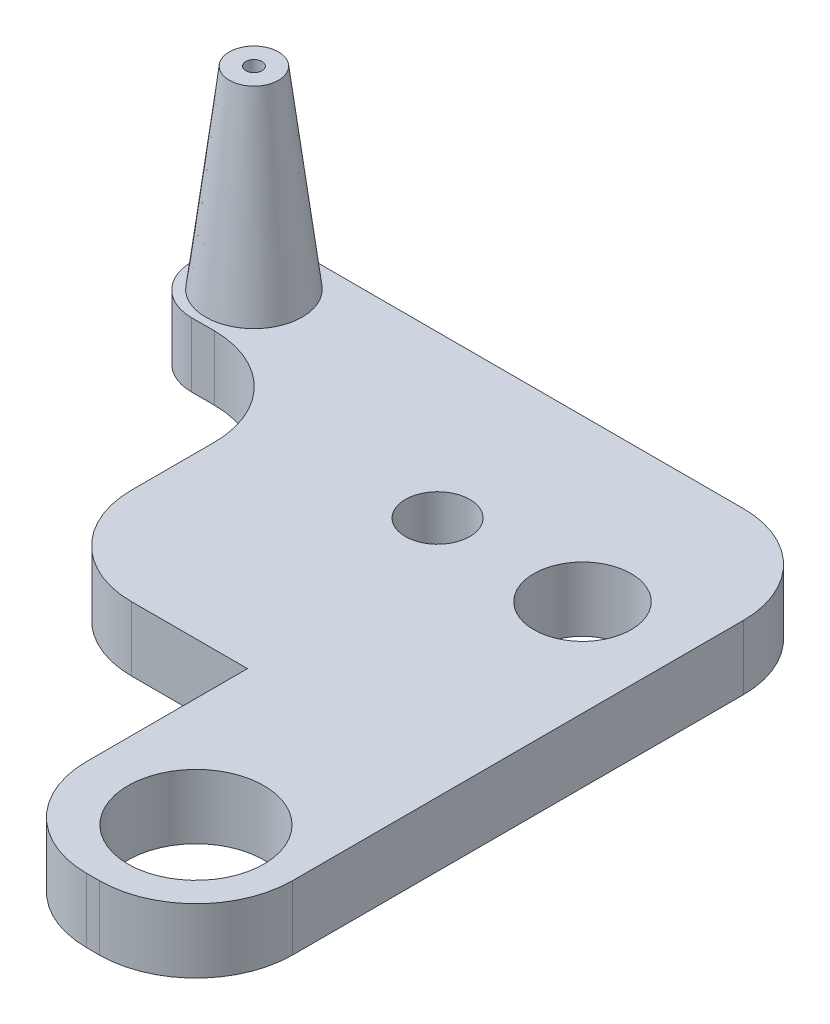
from build123d import *

# Parameters (mm, degrees)
SKETCH1_R           = 7.55
SKETCH1_R_2         = 5
SKETCH1_R_3         = 10.55
BOSS_EXTRUDE1_DEPTH = 10
SKETCH4_R           = 7.5
BOSS_EXTRUDE2_DEPTH = 30
BOSS_EXTRUDE2_TAPER = 7
SKETCH5_R           = 1.25
CUT_EXTRUDE2_DEPTH  = 10
FILLET1_R           = 15
FILLET2_R           = 7.5


with BuildPart() as part:
    # Sketch1 → Boss-Extrude1 (new body)
    with BuildSketch(Plane(origin=(0, 0, 0), x_dir=(1, 0, 0), z_dir=(0, 1, 0))):
        Polygon((23.995878661, -35), (56.995878661, -35), (56.995878661, -75), (88.995878661, -75), (88.995878661, -25), (88.995878661, 25), (17.5, 25), (-2.004121339, 25), (-2.004121339, 7.840472806), (23.995878661, 7.840472806), (23.995878661, 0), align=None)
        with Locations((73.995878661, 0)):
            Circle(SKETCH1_R, mode=Mode.SUBTRACT)
        with Locations((51.495878661, 0)):
            Circle(SKETCH1_R_2, mode=Mode.SUBTRACT)
        with Locations((73.995878661, -60)):
            Circle(SKETCH1_R_3, mode=Mode.SUBTRACT)
    extrude(amount=BOSS_EXTRUDE1_DEPTH)

    # Sketch4 → Boss-Extrude2 (add)
    with BuildSketch(Plane(origin=(0, 10, 0), x_dir=(1, 0, 0), z_dir=(0, 1, 0))):
        with Locations((6.495878661, 16.5)):
            Circle(SKETCH4_R)
    extrude(amount=BOSS_EXTRUDE2_DEPTH, taper=BOSS_EXTRUDE2_TAPER)

    # Sketch5 → Cut-Extrude2 (cut)
    with BuildSketch(Plane(origin=(0, 40, 0), x_dir=(1, 0, 0), z_dir=(0, 1, 0))):
        with Locations((6.495878661, 16.5)):
            Circle(SKETCH5_R)
    extrude(amount=-CUT_EXTRUDE2_DEPTH, mode=Mode.SUBTRACT)

    # Fillet1
    fillet1_edges = [part.edges().sort_by_distance(p)[0] for p in [
        (88.995878661, 5, -25),
        (88.995878661, 5, 75),
        (56.995878661, 5, 75),
        (23.995878661, 5, 35),
        (23.995878661, 5, -7.840472806),
    ]]
    fillet(fillet1_edges, radius=FILLET1_R)

    # Fillet2
    fillet2_edges = [part.edges().sort_by_distance(p)[0] for p in [
        (-2.004121339, 5, -7.840472806),
        (-2.004121339, 5, -25),
    ]]
    fillet(fillet2_edges, radius=FILLET2_R)


solid = part.part
